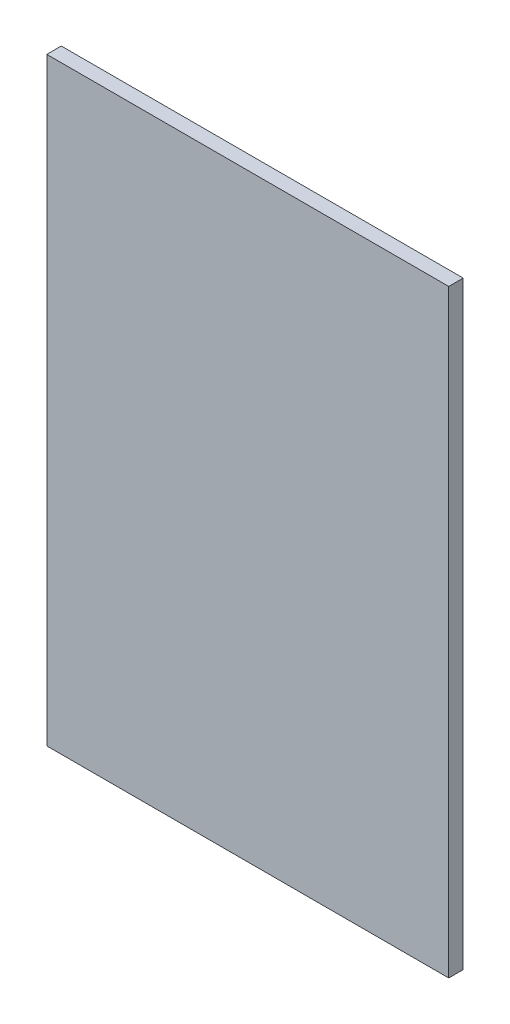
from build123d import *

# Parameters (mm, degrees)
SKETCH1_W           = 500
SKETCH1_H           = 745
BOSS_EXTRUDE1_DEPTH = 18


with BuildPart() as part:
    # Sketch1 → Boss-Extrude1 (new body)
    with BuildSketch(Plane.XY):
        Rectangle(SKETCH1_W, SKETCH1_H)
    extrude(amount=BOSS_EXTRUDE1_DEPTH)


solid = part.part
